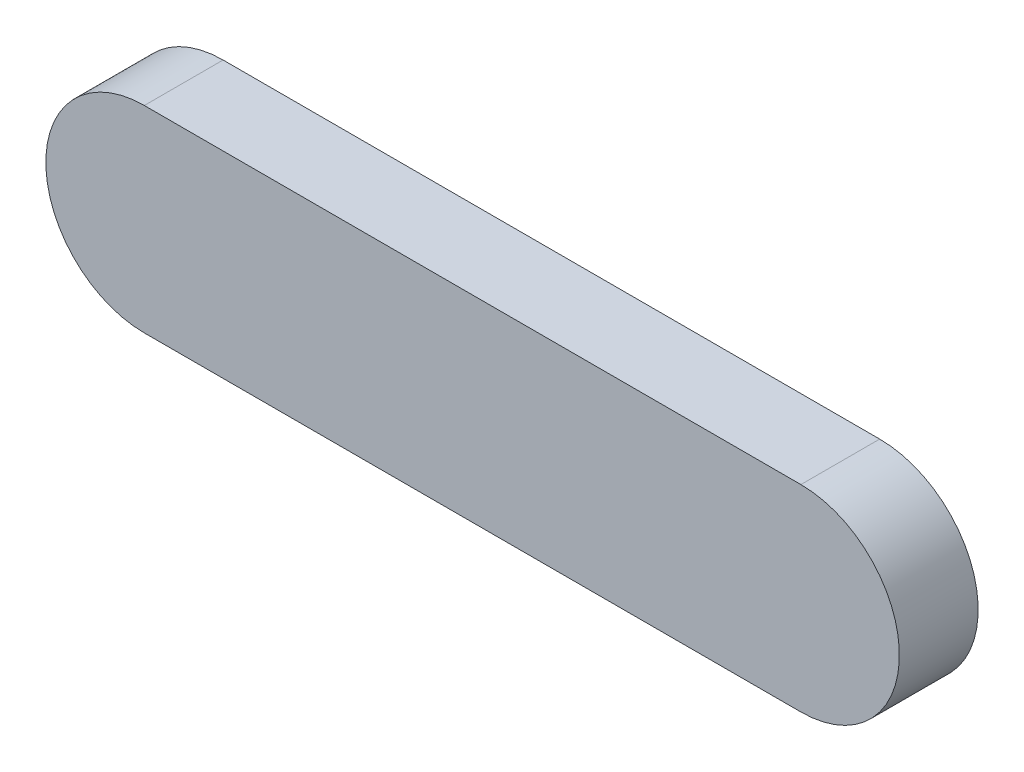
from build123d import *

# Parameters (mm, degrees)
EXTRUDE_1_DEPTH = 12


with BuildPart() as part:
    # 草图1 → 凸台-拉伸1 (new body)
    with BuildSketch(Plane.XY):
        with BuildLine():
            Line((-50, 25), (50, 25))
            ThreePointArc((50, 25), (65, 10), (50, -5))
            Line((50, -5), (-50, -5))
            ThreePointArc((-50, -5), (-65, 10), (-50, 25))
        make_face()
    extrude(amount=EXTRUDE_1_DEPTH)


solid = part.part
